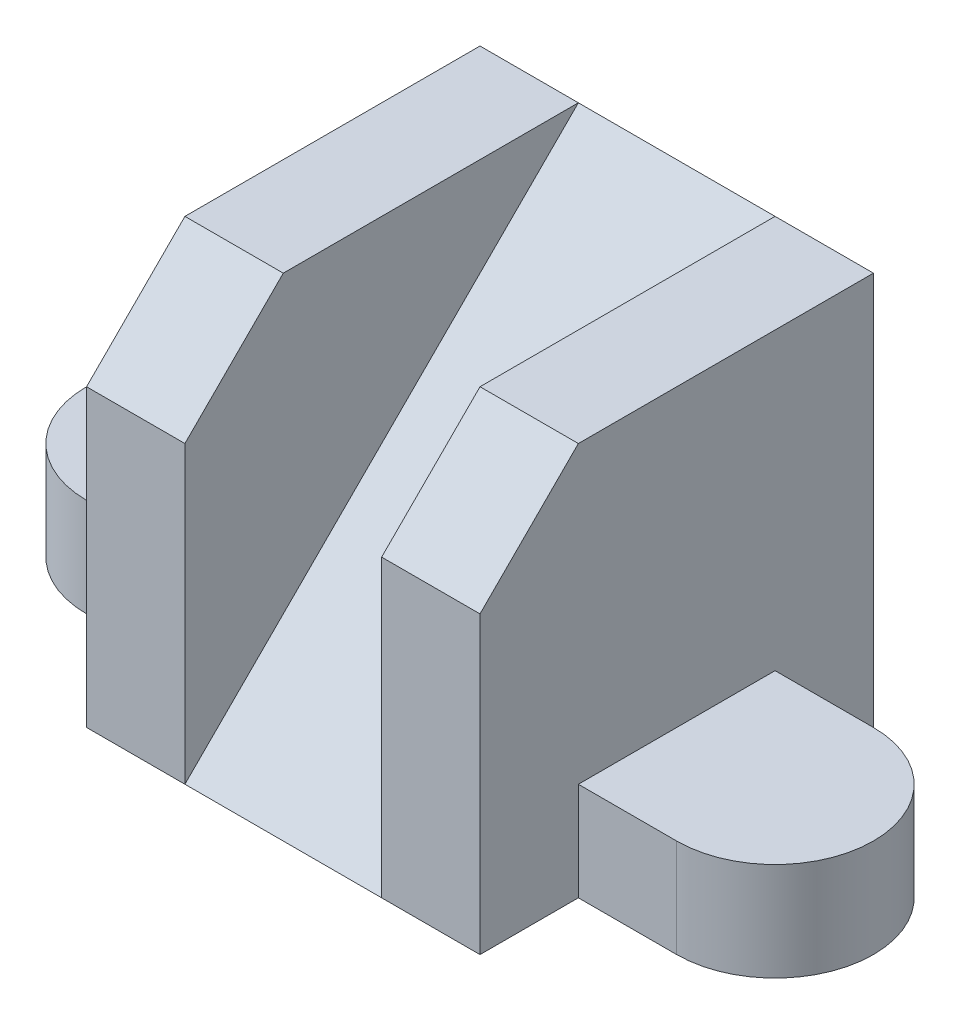
from build123d import *

# Parameters (mm, degrees)
EXTRUDE_1_DEPTH     = 14
CUT_EXTRUDE_1_DEPTH = 7
EXTRUDE_2_DEPTH     = 7


with BuildPart() as part:
    # 스케치1 → 보스-돌출1 (new body, symmetric)
    with BuildSketch(Plane(origin=(0, 0, 0), x_dir=(0, 0, -1), z_dir=(1, 0, 0))):
        Polygon((14, 0), (-14, 0), (-14, 21), (-7, 28), (14, 28), align=None)
    extrude(amount=EXTRUDE_1_DEPTH, both=True)

    # 스케치2 → 컷-돌출1 (cut, symmetric)
    with BuildSketch(Plane(origin=(0, 0, 0), x_dir=(0, 0, -1), z_dir=(1, 0, 0))):
        Polygon((-14, 0), (14, 28), (-14, 28), align=None)
    extrude(amount=CUT_EXTRUDE_1_DEPTH, both=True, mode=Mode.SUBTRACT)

    # 스케치3 → 보스-돌출2 (add)
    with BuildSketch(Plane(origin=(0, 0, 0), x_dir=(1, 0, 0), z_dir=(0, 1, 0))):
        with BuildLine():
            Line((-21, 7), (-14, 7))
            Line((-14, 7), (-14, -7))
            Line((-14, -7), (-21, -7))
            ThreePointArc((-21, -7), (-28, 0), (-21, 7))
        make_face()
        with BuildLine():
            Line((14, 7), (14, -7))
            Line((14, -7), (21, -7))
            ThreePointArc((21, -7), (28, 0), (21, 7))
            Line((21, 7), (14, 7))
        make_face()
    extrude(amount=EXTRUDE_2_DEPTH)


solid = part.part
